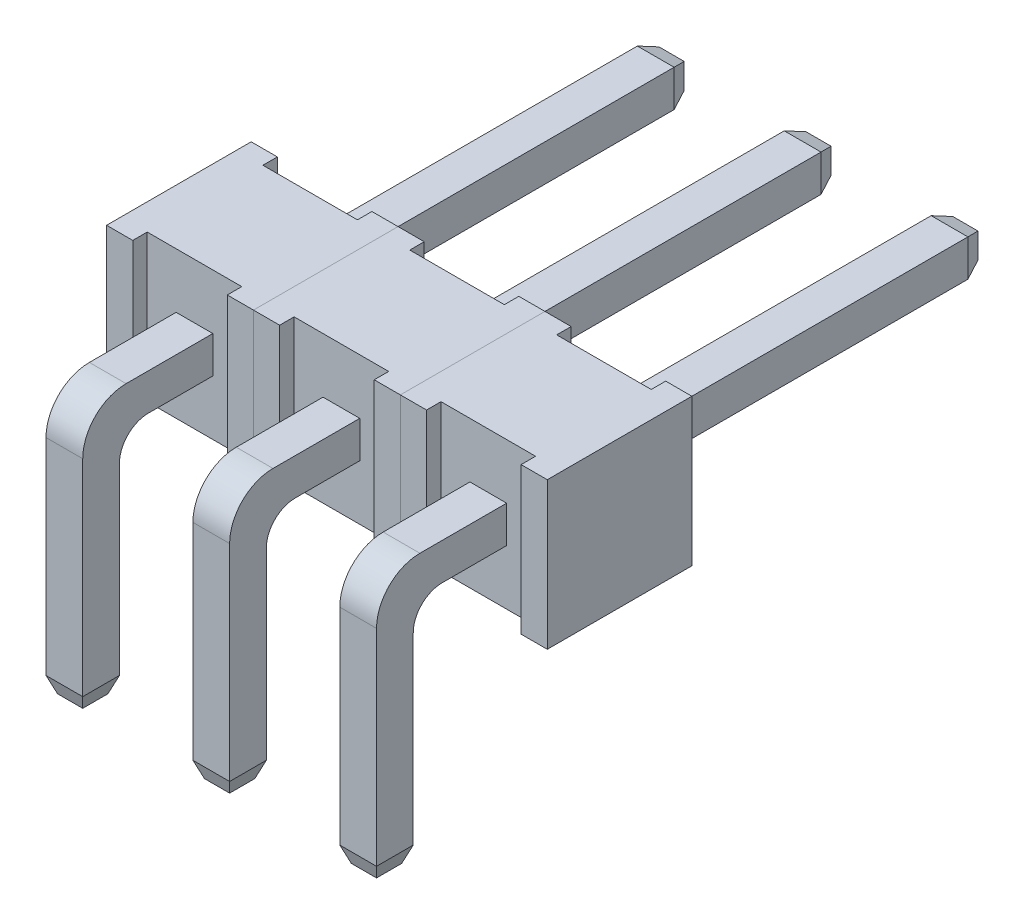
from build123d import *

# Parameters (mm, degrees)
SKETCH2_W             = 0.635
SKETCH2_H             = 4.5875
BOSS_EXTRUDE1_DEPTH   = 0.635
SKETCH3_W             = 0.635
SKETCH3_H             = 0.635
BOSS_EXTRUDE2_DEPTH   = 9.865
FILLET1_R             = 0.5
FILLET2_R             = 0.75
SKETCH4_W             = 0.4525
SKETCH4_H             = 2.54
BOSS_EXTRUDE3_DEPTH   = 0.25
BOSS_EXTRUDE3_2_DEPTH = 0.25
SKETCH5_W             = 2.54
SKETCH5_H             = 2.54
BOSS_EXTRUDE4_DEPTH   = 2
SKETCH6_W             = 0.4525
SKETCH6_H             = 2.54
BOSS_EXTRUDE5_DEPTH   = 0.25
CHAMFER1_SIZE         = 0.1
CHAMFER1_SIZE2        = 0.274747742
CHAMFER2_SIZE         = 0.1
CHAMFER2_SIZE2        = 0.274747742
NUM_PINS_COUNT        = 3
NUM_PINS_PITCH        = 2.54


with BuildPart() as part:
    # Sketch2 → Boss-Extrude1 (new body)
    with BuildSketch(Plane.XY):
        with Locations((1.27, 2.29375)):
            Rectangle(SKETCH2_W, SKETCH2_H)
    extrude(amount=-BOSS_EXTRUDE1_DEPTH)

    # Sketch3 → Boss-Extrude2 (add)
    with BuildSketch(Plane(origin=(0, 0, -0.635), x_dir=(-1, 0, 0), z_dir=(0, 0, -1))):
        with Locations((-1.27, 4.27)):
            Rectangle(SKETCH3_W, SKETCH3_H)
    extrude(amount=BOSS_EXTRUDE2_DEPTH)

    # Fillet1
    fillet1_edges = [part.edges().sort_by_distance(p)[0] for p in [
        (1.27, 3.9525, -0.635),
    ]]
    fillet(fillet1_edges, radius=FILLET1_R)

    # Fillet2
    fillet2_edges = [part.edges().sort_by_distance(p)[0] for p in [
        (1.27, 4.5875, 0),
    ]]
    fillet(fillet2_edges, radius=FILLET2_R)



with BuildPart() as body_2:
    # Sketch4 → Boss-Extrude3 (new body)
    with BuildSketch(Plane(origin=(0, 0, -2), x_dir=(-1, 0, 0), z_dir=(0, 0, -1))):
        with Locations((-0.22625, 4.27)):
            Rectangle(SKETCH4_W, SKETCH4_H)
    extrude(amount=BOSS_EXTRUDE3_DEPTH)


with BuildPart() as body_3:
    # Sketch4 → Boss-Extrude3 2 (new body)
    with BuildSketch(Plane(origin=(0, 0, -2), x_dir=(-1, 0, 0), z_dir=(0, 0, -1))):
        with Locations((-2.31375, 4.27)):
            Rectangle(SKETCH4_W, SKETCH4_H)
    extrude(amount=BOSS_EXTRUDE3_2_DEPTH)


with BuildPart() as part_1:
    add(part.part)

    add(body_2.part)  # Boss-Extrude4 merges body 2

    add(body_3.part)  # Boss-Extrude4 merges body 3
    # Sketch5 → Boss-Extrude4 (add)
    with BuildSketch(Plane(origin=(0, 0, -2.25), x_dir=(-1, 0, 0), z_dir=(0, 0, -1))):
        with Locations((-1.27, 4.27)):
            Rectangle(SKETCH5_W, SKETCH5_H)
    extrude(amount=BOSS_EXTRUDE4_DEPTH)

    # Sketch6 → Boss-Extrude5 (add)
    with BuildSketch(Plane(origin=(0, 0, -4.25), x_dir=(-1, 0, 0), z_dir=(0, 0, -1))):
        with Locations((-0.22625, 4.27)):
            Rectangle(SKETCH6_W, SKETCH6_H)
        with Locations((-2.31375, 4.27)):
            Rectangle(SKETCH6_W, SKETCH6_H)
    extrude(amount=BOSS_EXTRUDE5_DEPTH)

    # Chamfer1
    chamfer1_edges = [part_1.edges().sort_by_distance(p)[0] for p in [
        (1.27, 3.9525, -10.5),
        (0.9525, 4.27, -10.5),
        (1.27, 4.5875, -10.5),
        (1.5875, 4.27, -10.5),
    ]]
    chamfer1_side = [part_1.faces().sort_by_distance(p)[0] for p in [
        (1.27, 4.27, -10.5),
    ]]
    chamfer(chamfer1_edges, length=CHAMFER1_SIZE, length2=CHAMFER1_SIZE2, reference=chamfer1_side[0])

    # Chamfer2
    chamfer2_edges = [part_1.edges().sort_by_distance(p)[0] for p in [
        (1.27, 0, 0),
        (1.5875, 0, -0.3175),
        (0.9525, 0, -0.3175),
        (1.27, 0, -0.635),
    ]]
    chamfer2_side = [part_1.faces().sort_by_distance(p)[0] for p in [
        (1.27, 0, -0.3175),
    ]]
    chamfer(chamfer2_edges, length=CHAMFER2_SIZE, length2=CHAMFER2_SIZE2, reference=chamfer2_side[0])


with BuildPart() as num_pins_1:
    # Num pins: pattern copy
    add(part_1.part.moved(Location(Vector(1, 0, 0) * (1 * NUM_PINS_PITCH))))


with BuildPart() as num_pins_2:
    # Num pins: pattern copy
    add(part_1.part.moved(Location(Vector(1, 0, 0) * (2 * NUM_PINS_PITCH))))


solid = Compound([part_1.part, num_pins_1.part, num_pins_2.part])
